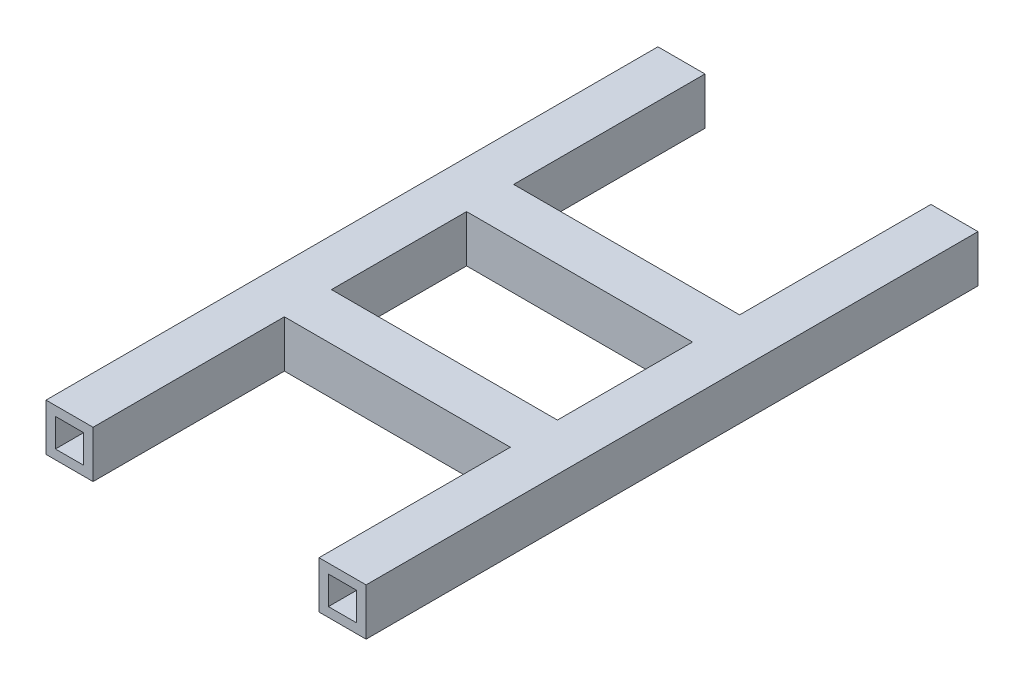
from build123d import *

# Parameters (mm, degrees)
SKETCH1_W               = 50
SKETCH1_H               = 50
SKETCH1_W_2             = 30
SKETCH1_H_2             = 30
BOSS_EXTRUDE1_DEPTH     = 650
BOSS_EXTRUDE1_2_DEPTH   = 650
SKETCH2_R               = 10
CUT_EXTRUDE1_DEPTH      = 18
CUT_EXTRUDE1_DEPTH_BACK = 13
SKETCH3_W               = 50
SKETCH3_H               = 50
SKETCH3_W_2             = 30
SKETCH3_H_2             = 30
BOSS_EXTRUDE3_DEPTH     = 240


with BuildPart() as part:
    # Sketch1 → Boss-Extrude1 (new body)
    with BuildSketch(Plane.XY):
        Rectangle(SKETCH1_W, SKETCH1_H)
        Rectangle(SKETCH1_W_2, SKETCH1_H_2, mode=Mode.SUBTRACT)
    extrude(amount=BOSS_EXTRUDE1_DEPTH)


with BuildPart() as body_2:
    # Sketch1 → Boss-Extrude1 2 (new body)
    with BuildSketch(Plane.XY):
        with Locations((290, 0)):
            Rectangle(SKETCH1_W, SKETCH1_H)
        with Locations((290, 0)):
            Rectangle(SKETCH1_W_2, SKETCH1_H_2, mode=Mode.SUBTRACT)
    extrude(amount=BOSS_EXTRUDE1_2_DEPTH)


with BuildPart() as cut_extrude1_tool:
    # Sketch2 → Cut-Extrude1 (new body, two sides)
    with BuildSketch(Plane.XZ.offset(25)) as cut_extrude1_sk:
        with Locations((290, 600)):
            Circle(SKETCH2_R)
        with Locations((290, 550)):
            Circle(SKETCH2_R)
        with Locations((290, 500)):
            Circle(SKETCH2_R)
        with Locations((290, 150)):
            Circle(SKETCH2_R)
        with Locations((290, 100)):
            Circle(SKETCH2_R)
        with Locations((290, 50)):
            Circle(SKETCH2_R)
        with Locations((0, 500)):
            Circle(SKETCH2_R)
        with Locations((0, 550)):
            Circle(SKETCH2_R)
        with Locations((0, 600)):
            Circle(SKETCH2_R)
        with Locations((0, 50)):
            Circle(SKETCH2_R)
        with Locations((0, 100)):
            Circle(SKETCH2_R)
        with Locations((0, 150)):
            Circle(SKETCH2_R)
    extrude(amount=CUT_EXTRUDE1_DEPTH)
    extrude(cut_extrude1_sk.sketch, amount=-CUT_EXTRUDE1_DEPTH_BACK)


with BuildPart() as part_1:
    add(part.part)

    # Cut-Extrude1: cut by cut_extrude1_tool
    add(cut_extrude1_tool.part, mode=Mode.SUBTRACT)



with BuildPart() as body_2_1:
    add(body_2.part)

    # Cut-Extrude1: cut by cut_extrude1_tool
    add(cut_extrude1_tool.part, mode=Mode.SUBTRACT)


with BuildPart() as part_2:
    add(part_1.part)

    add(body_2_1.part)  # Boss-Extrude3 merges body 2
    # Sketch3 → Boss-Extrude3 (add)
    with BuildSketch(Plane.ZY.offset(-265)):
        with Locations((421.770995298, 0)):
            Rectangle(SKETCH3_W, SKETCH3_H)
        with Locations((421.770995298, 0)):
            Rectangle(SKETCH3_W_2, SKETCH3_H_2, mode=Mode.SUBTRACT)
        with Locations((228.229004702, 0)):
            Rectangle(SKETCH3_W, SKETCH3_H)
        with Locations((228.229004702, 0)):
            Rectangle(SKETCH3_W_2, SKETCH3_H_2, mode=Mode.SUBTRACT)
    extrude(amount=BOSS_EXTRUDE3_DEPTH)


solid = part_2.part
